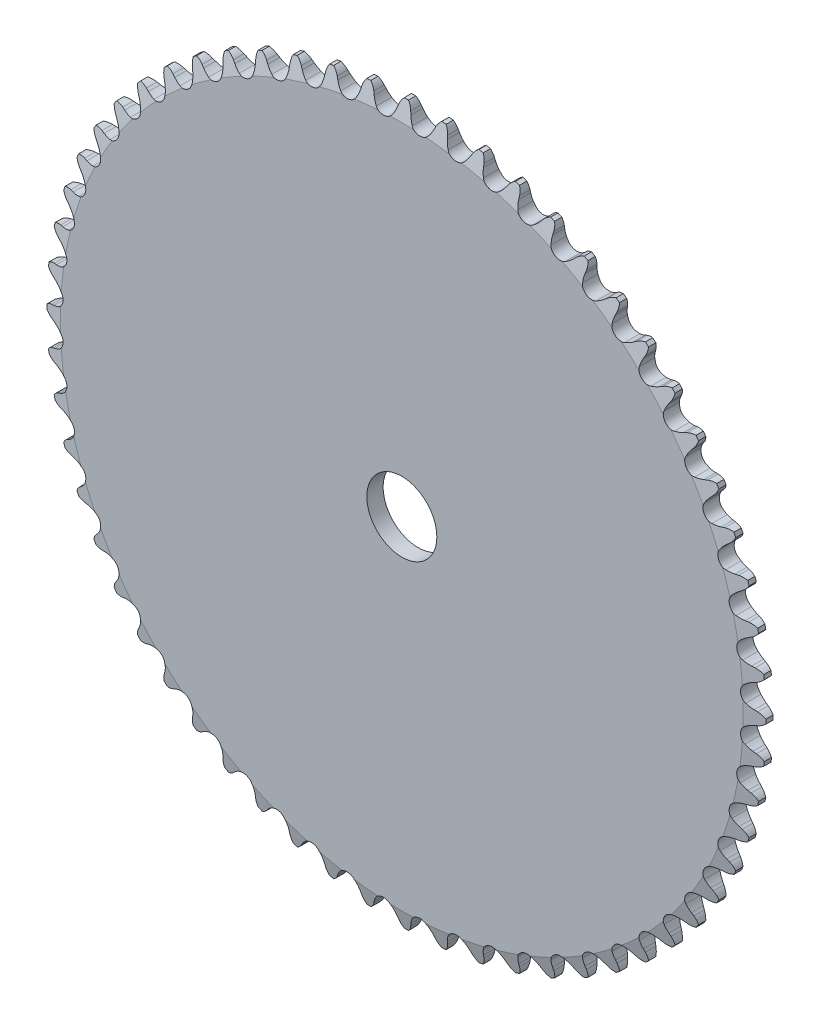
from build123d import *

# Parameters (mm, degrees)
CUT_EXTRUDE1_DEPTH      = 133.573406055
CIRPATTERN1_COUNT       = 60
SKETCH3_OUTSIDE_W       = 242.492
SKETCH3_OUTSIDE_H       = 242.492
SKETCH3_OUTSIDE_R       = 93.726
SKETCH3_OUTSIDE_R_2     = 9.128125
CUT_EXTRUDE2_DEPTH      = 133.573406198
CUT_EXTRUDE2_DEPTH_BACK = 133.573406198


with BuildPart() as part:
    # Sketch1 → Revolve1 (revolve)
    with BuildSketch(Plane(origin=(0, 0, 0), x_dir=(0, 0, -1), z_dir=(1, 0, 0)), mode=Mode.PRIVATE) as revolve1_sk:
        Polygon((2.1336, 0), (-2.1336, 0), (-2.1336, 88.968913475), (-0.942975, 93.731413475), (0.942975, 93.731413475), (2.1336, 88.968913475), align=None)
    revolve(revolve1_sk.sketch.rotate(Axis((0, 0, -2.1336), (0, 0, 1)), 90), axis=Axis((0, 0, -2.1336), (0, 0, 1)))

    # Sketch0 → Cut-Extrude1 (cut, symmetric)
    with BuildSketch(Plane.XY):
        with BuildLine():
            Line((8.061051224, -91.65039306), (7.777298409, -90.945720653))
            ThreePointArc((7.777298409, -90.945720653), (7.340112567, -90.057241706), (6.775929757, -89.243470206))
            ThreePointArc((6.775929757, -89.243470206), (4.626908005, -88.286664077), (2.589672293, -89.462862663))
            ThreePointArc((2.589672293, -89.462862663), (2.113642419, -90.3311494), (1.771722866, -91.260459531))
            Line((1.771722866, -91.260459531), (1.563182803, -91.990931914))
            ThreePointArc((1.563182803, -91.990931914), (0.0589948, -94.153542983), (-2.454667012, -94.941561052))
            ThreePointArc((-2.454667012, -94.941561052), (4.970517837, -94.84313026), (12.365315567, -94.164878676))
            ThreePointArc((12.365315567, -94.164878676), (9.783053539, -93.643926659), (8.061051224, -91.65039306))
        make_face()
    cut_extrude1 = extrude(amount=CUT_EXTRUDE1_DEPTH, both=True, mode=Mode.SUBTRACT)

    # CirPattern1: Cut-Extrude1 ×60 about axis
    cirpattern1_axis = Axis((0, 0, 0), (0, 0, 1))
    for i in range(1, CIRPATTERN1_COUNT):
        add(cut_extrude1.rotate(cirpattern1_axis, i * 360 / CIRPATTERN1_COUNT), mode=Mode.SUBTRACT)

    # Sketch3 outside → Cut-Extrude2 (cut, two sides)
    with BuildSketch(Plane.XY) as cut_extrude2_sk:
        Rectangle(SKETCH3_OUTSIDE_W, SKETCH3_OUTSIDE_H)
        Circle(SKETCH3_OUTSIDE_R, mode=Mode.SUBTRACT)
        Circle(SKETCH3_OUTSIDE_R_2)
    extrude(amount=CUT_EXTRUDE2_DEPTH, mode=Mode.SUBTRACT)
    extrude(cut_extrude2_sk.sketch, amount=-CUT_EXTRUDE2_DEPTH_BACK, mode=Mode.SUBTRACT)


solid = part.part
